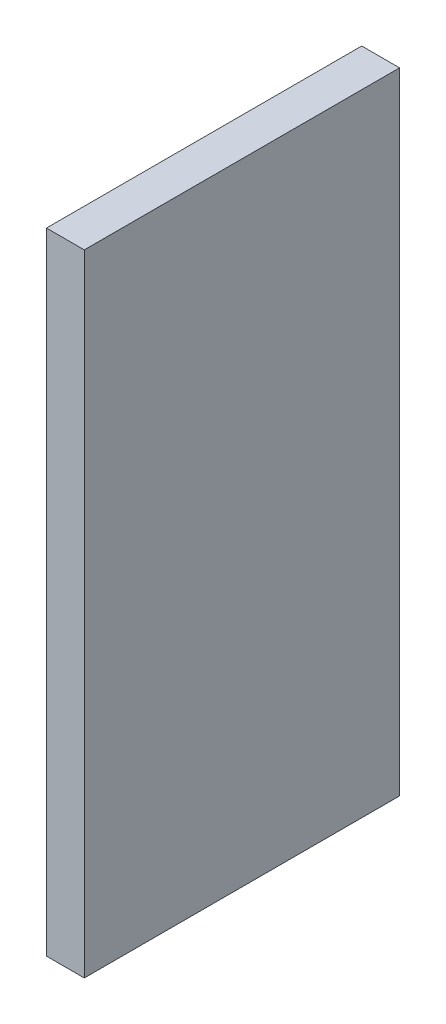
from build123d import *

# Parameters (mm, degrees)
SKETCH1_W           = 25
SKETCH1_H           = 50
BOSS_EXTRUDE1_DEPTH = 3


with BuildPart() as part:
    # Sketch1 → Boss-Extrude1 (new body)
    with BuildSketch(Plane(origin=(0, 0, 0), x_dir=(0, 0, -1), z_dir=(1, 0, 0))):
        Rectangle(SKETCH1_W, SKETCH1_H)
    extrude(amount=BOSS_EXTRUDE1_DEPTH)


solid = part.part
